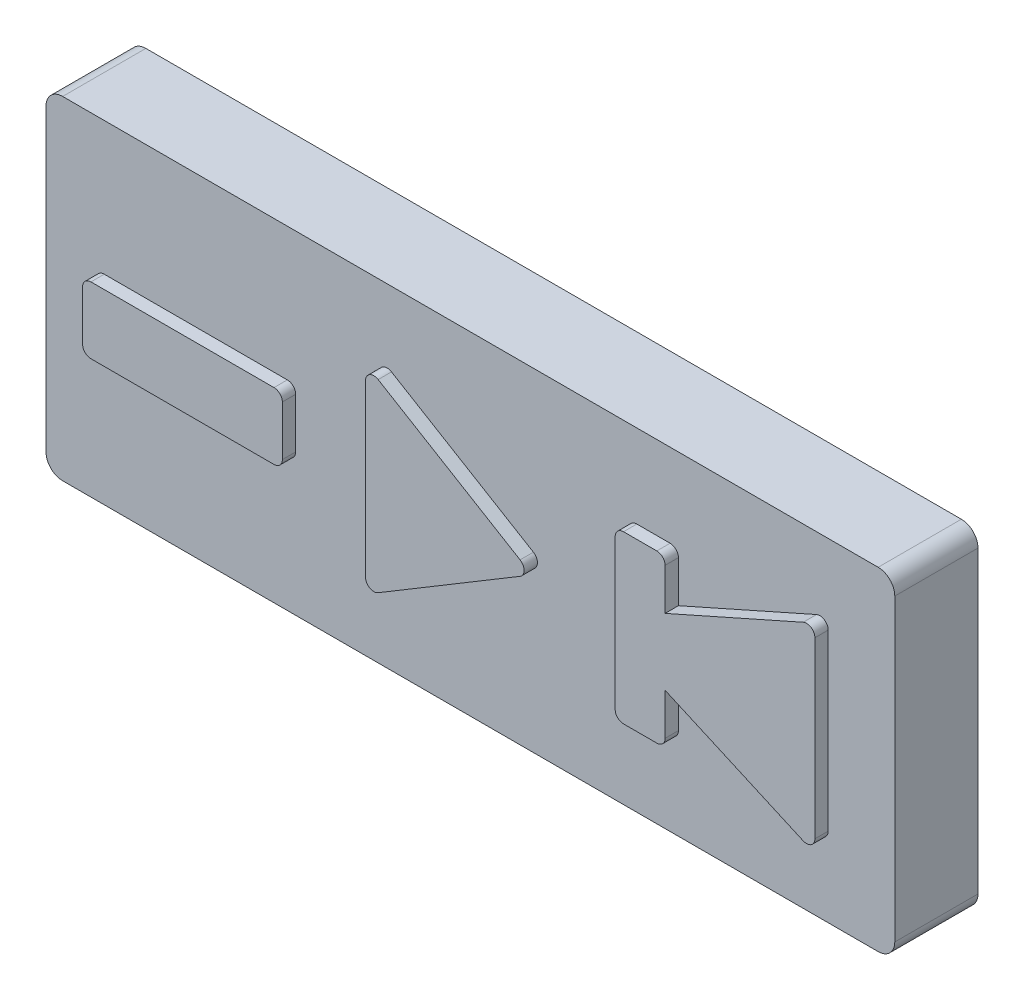
from build123d import *

# Parameters (mm, degrees)
BOSS_EXTRUDE1_DEPTH = 5
SKETCH6_R           = 0.75
CUT_EXTRUDE1_DEPTH  = 1
BOSS_EXTRUDE3_DEPTH = 0.8


with BuildPart() as part:
    # Sketch3 → Boss-Extrude1 (new body)
    with BuildSketch(Plane.XY):
        with BuildLine():
            Line((-24, 10), (25, 10))
            ThreePointArc((25, 10), (25.707106781, 9.707106781), (26, 9))
            Line((26, 9), (26, -9))
            ThreePointArc((26, -9), (25.707106781, -9.707106781), (25, -10))
            Line((25, -10), (-24, -10))
            ThreePointArc((-24, -10), (-24.707106781, -9.707106781), (-25, -9))
            Line((-25, -9), (-25, 9))
            ThreePointArc((-25, 9), (-24.707106781, 9.707106781), (-24, 10))
        make_face()
    extrude(amount=BOSS_EXTRUDE1_DEPTH)

    # Sketch6 → Cut-Extrude1 (cut)
    with BuildSketch(Plane.XY):
        with Locations((-16, 0)):
            Circle(SKETCH6_R)
        with Locations((-1, 0)):
            Circle(SKETCH6_R)
        with Locations((17, 0)):
            Circle(SKETCH6_R)
    extrude(amount=CUT_EXTRUDE1_DEPTH, mode=Mode.SUBTRACT)

    # Sketch4 → Boss-Extrude3 (add)
    with BuildSketch(Plane.XY.offset(5)):
        with BuildLine():
            Line((-5, 5.116904811), (-5, -5.116904811))
            ThreePointArc((-5, -5.116904811), (-4.746349407, -5.552004764), (-4.242752122, -5.545651273))
            Line((-4.242752122, -5.545651273), (4.285422562, -0.428746463))
            ThreePointArc((4.285422562, -0.428746463), (4.528174684, 0), (4.285422562, 0.428746463))
            Line((4.285422562, 0.428746463), (-4.242752122, 5.545651273))
            ThreePointArc((-4.242752122, 5.545651273), (-4.746349407, 5.552004764), (-5, 5.116904811))
        make_face()
        with BuildLine():
            Line((10, 4.5), (10, -4.5))
            ThreePointArc((10, -4.5), (10.146446609, -4.853553391), (10.5, -5))
            Line((10.5, -5), (12.5, -5))
            ThreePointArc((12.5, -5), (12.853553391, -4.853553391), (13, -4.5))
            Line((13, -4.5), (13, -2))
            Line((13, -2), (21.296930767, -5.687524785))
            ThreePointArc((21.296930767, -5.687524785), (21.77245677, -5.64986513), (22, -5.230619011))
            Line((22, -5.230619011), (22, 5.230619011))
            ThreePointArc((22, 5.230619011), (21.77245677, 5.64986513), (21.296930767, 5.687524785))
            Line((21.296930767, 5.687524785), (13, 2))
            Line((13, 2), (13, 4.5))
            ThreePointArc((13, 4.5), (12.853553391, 4.853553391), (12.5, 5))
            Line((12.5, 5), (10.5, 5))
            ThreePointArc((10.5, 5), (10.146446609, 4.853553391), (10, 4.5))
        make_face()
        with BuildLine():
            Line((-21.5, 2), (-10.5, 2))
            ThreePointArc((-10.5, 2), (-10.146446609, 1.853553391), (-10, 1.5))
            Line((-10, 1.5), (-10, -1.5))
            ThreePointArc((-10, -1.5), (-10.146446609, -1.853553391), (-10.5, -2))
            Line((-10.5, -2), (-21.5, -2))
            ThreePointArc((-21.5, -2), (-21.853553391, -1.853553391), (-22, -1.5))
            Line((-22, -1.5), (-22, 1.5))
            ThreePointArc((-22, 1.5), (-21.853553391, 1.853553391), (-21.5, 2))
        make_face()
    extrude(amount=BOSS_EXTRUDE3_DEPTH)


solid = part.part
